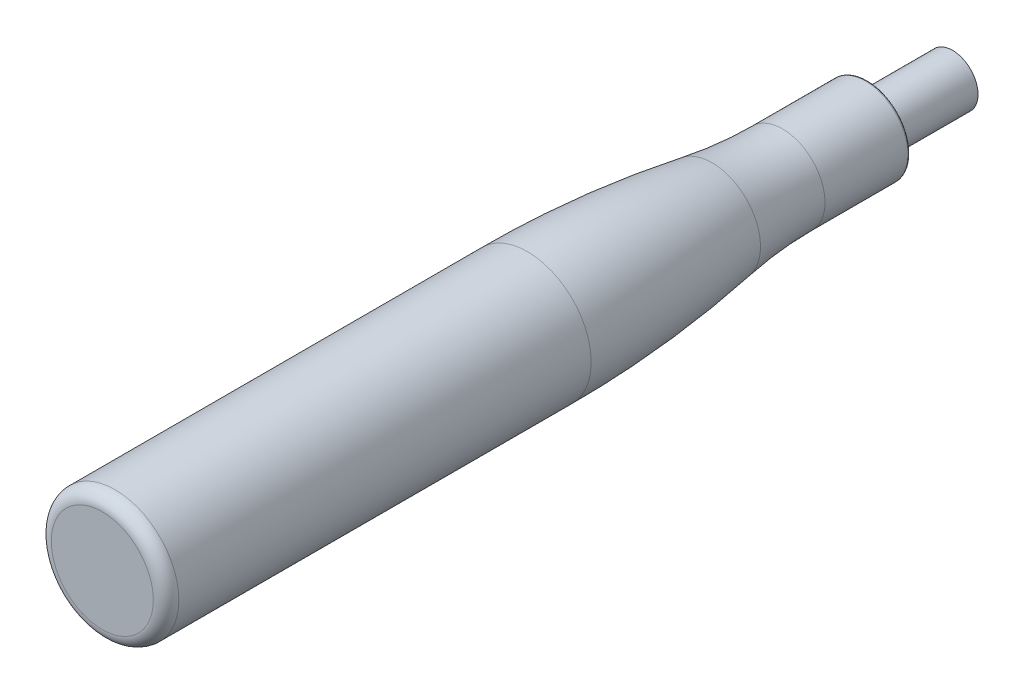
from build123d import *

# Parameters (mm, degrees)
FILLET1_R = 1.5
FILLET2_R = 0.25


with BuildPart() as part:
    # Sketch2 → Revolve1 (revolve)
    with BuildSketch(Plane(origin=(0, 0, 0), x_dir=(0, 0, -1), z_dir=(1, 0, 0))):
        with BuildLine():
            Line((-90, 0), (10, 0))
            Line((10, 0), (10, 3))
            Line((10, 3), (0, 3))
            Line((0, 3), (0, 5))
            Line((0, 5), (-10, 5))
            ThreePointArc((-10, 5), (-14.152273993, 5.172712088), (-18.275862069, 5.689655172))
            ThreePointArc((-18.275862069, 5.689655172), (-29.100280769, 7.04663077), (-40, 7.5))
            Line((-40, 7.5), (-90, 7.5))
            Line((-90, 7.5), (-90, 0))
        make_face()
    revolve(axis=Axis((0, 0, -121.417180302), (0, 0, 1)))

    # Fillet1
    fillet1_edges = [part.edges().sort_by_distance(p)[0] for p in [
        (0, -7.5, 90),
    ]]
    fillet(fillet1_edges, radius=FILLET1_R)

    # Fillet2
    fillet2_edges = [part.edges().sort_by_distance(p)[0] for p in [
        (0, -5, 0),
    ]]
    fillet(fillet2_edges, radius=FILLET2_R)


solid = part.part
